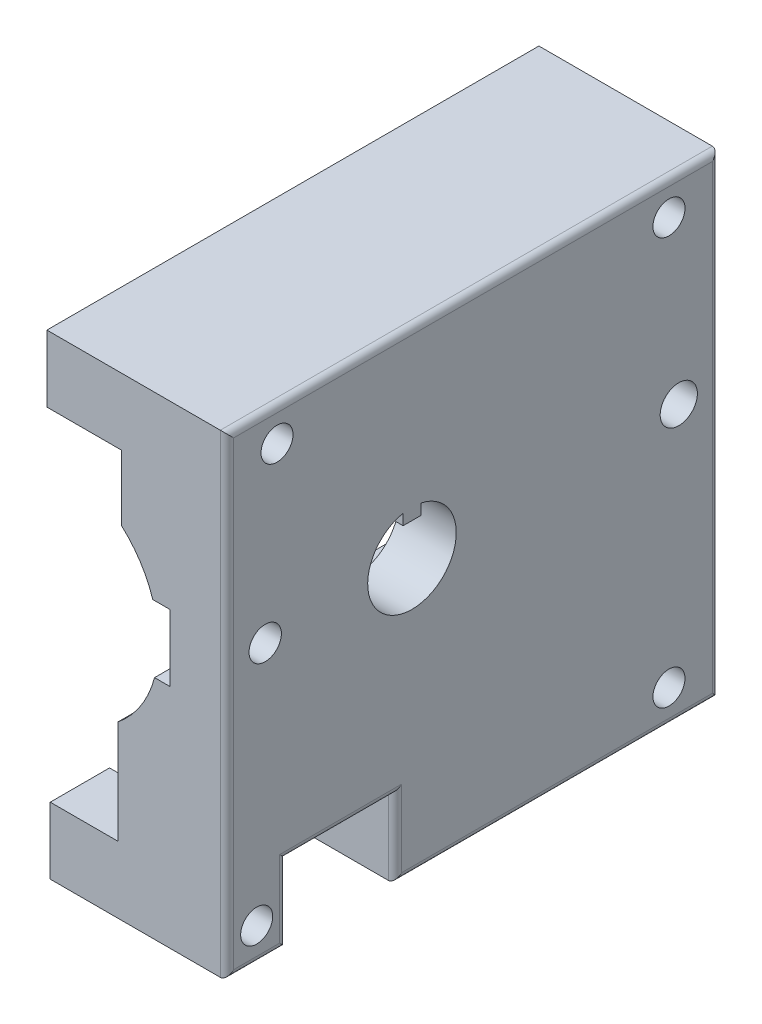
from build123d import *

# Parameters (mm, degrees)
PROFILEEXTRUDE_DEPTH = 73.76
HOSEWINDOW_W         = 16.29
HOSEWINDOW_H         = 11.5
HOSEWINDOWCUT_DEPTH  = 28
CAGESCREWS_R         = 2.4
CAGESCREWSCUT_DEPTH  = 28
AXLEHOLECUT_DEPTH    = 28
SETSCREWS_R          = 2.426338021
SETSCREWS_R_2        = 2.788762315
SETSCREWSCUT_DEPTH   = 28
FILLET1_R            = 1


with BuildPart() as part:
    # Profile → ProfileExtrude (new body)
    with BuildSketch(Plane.XY):
        with BuildLine():
            Line((-6.01073477, -43.62791746), (-6.01073477, -33.62791746))
            Line((-6.01073477, -33.62791746), (4.13926523, -33.62791746))
            Line((4.13926523, -33.62791746), (4.13926523, -18.13791746))
            ThreePointArc((4.13926523, -18.13791746), (7.563334043, -14.326029686), (9.63126523, -9.63791746))
            Line((9.63126523, -9.63791746), (11.94926523, -9.63791746))
            Line((11.94926523, -9.63791746), (11.94926523, 0.36208254))
            Line((11.94926523, 0.36208254), (9.35926523, 0.36208254))
            ThreePointArc((9.35926523, 0.36208254), (7.493178347, 4.320032013), (4.63926523, 7.63708254))
            Line((4.63926523, 7.63708254), (4.63926523, 17.41208254))
            Line((4.63926523, 17.41208254), (-6.51073477, 17.41208254))
            Line((-6.51073477, 17.41208254), (-6.51073477, 27.41208254))
            Line((-6.51073477, 27.41208254), (20.48926523, 27.41208254))
            Line((20.48926523, 27.41208254), (20.48926523, -43.62791746))
            Line((20.48926523, -43.62791746), (-6.01073477, -43.62791746))
        make_face()
    extrude(amount=PROFILEEXTRUDE_DEPTH)

    # HoseWindow → HoseWindowCut (cut, through all)
    with BuildSketch(Plane(origin=(20.48926523, 0, 0), x_dir=(0, 0, -1), z_dir=(1, 0, 0))):
        with Locations((-56.725, -37.87791746)):
            Rectangle(HOSEWINDOW_W, HOSEWINDOW_H)
    extrude(amount=-HOSEWINDOWCUT_DEPTH, mode=Mode.SUBTRACT)

    # CageScrews → CageScrewsCut (cut, through all)
    with BuildSketch(Plane(origin=(20.48926523, 0, 0), x_dir=(0, 0, -1), z_dir=(1, 0, 0))):
        with Locations((-66.26, 22.41208254)):
            Circle(CAGESCREWS_R)
        with Locations((-7.5, 22.41208254)):
            Circle(CAGESCREWS_R)
        with Locations((-7.5, -38.62791746)):
            Circle(CAGESCREWS_R)
        with Locations((-69.31, -38.62791746)):
            Circle(CAGESCREWS_R)
    extrude(amount=-CAGESCREWSCUT_DEPTH, mode=Mode.SUBTRACT)

    # AxleHole → AxleHoleCut (cut, through all)
    with BuildSketch(Plane(origin=(20.48926523, 0, 0), x_dir=(0, 0, -1), z_dir=(1, 0, 0))):
        with BuildLine():
            Line((-44.699, 2.307293484), (-47.361, 2.307293484))
            Line((-47.361, 2.307293484), (-47.361, 3.926293484))
            ThreePointArc((-47.361, 3.926293484), (-46.03, -9.21691746), (-44.699, 3.926293484))
            Line((-44.699, 3.926293484), (-44.699, 2.307293484))
        make_face()
    extrude(amount=-AXLEHOLECUT_DEPTH, mode=Mode.SUBTRACT)

    # SetScrews → SetScrewsCut (cut, through all)
    with BuildSketch(Plane(origin=(20.48926523, 0, 0), x_dir=(0, 0, -1), z_dir=(1, 0, 0))):
        with Locations((-68.03, -2.57791746)):
            Circle(SETSCREWS_R)
        with Locations((-6.03, -2.57791746)):
            Circle(SETSCREWS_R_2)
    extrude(amount=-SETSCREWSCUT_DEPTH, mode=Mode.SUBTRACT)

    # Fillet1
    fillet1_edges = [part.edges().sort_by_distance(p)[0] for p in [
        (20.48926523, -8.10791746, 0),
        (20.48926523, -43.62791746, 69.315),
        (20.48926523, 27.41208254, 36.88),
        (20.48926523, -8.10791746, 73.76),
        (20.48926523, -43.62791746, 24.29),
        (20.48926523, -37.87791746, 64.87),
        (20.48926523, -37.87791746, 48.58),
        (20.48926523, -32.12791746, 56.725),
    ]]
    fillet(fillet1_edges, radius=FILLET1_R)


solid = part.part
